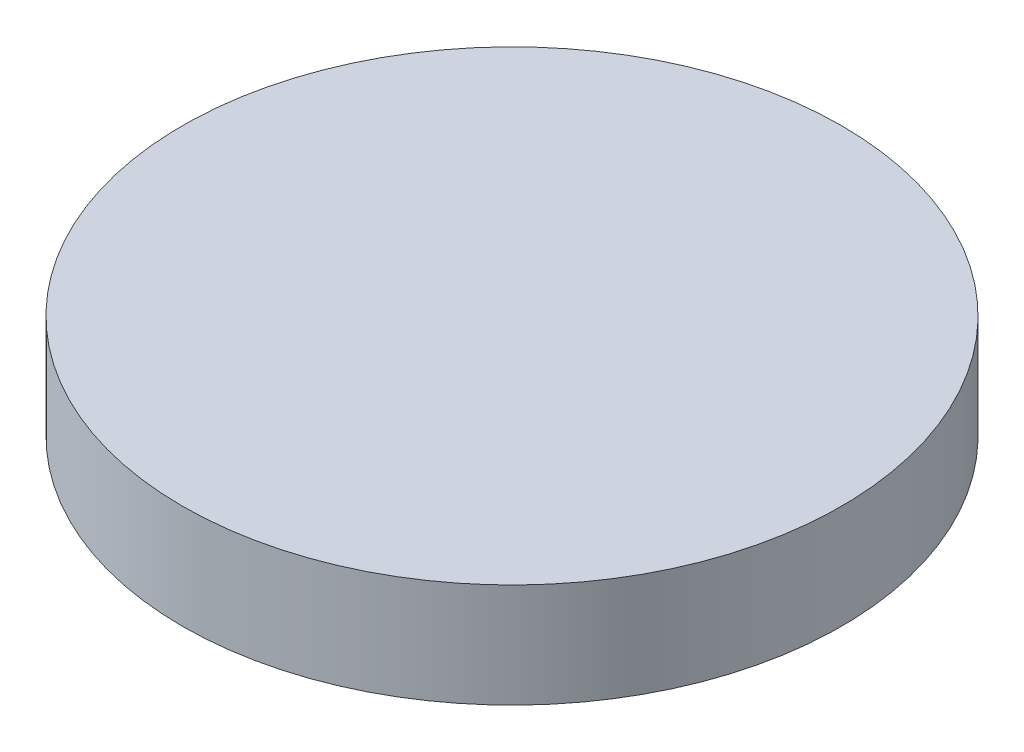
from build123d import *

# Parameters (mm, degrees)
SKETCH1_R           = 60.325
BOSS_EXTRUDE1_DEPTH = 19.05
SKETCH2_R           = 57.15
SKETCH2_R_2         = 55.5625
CUT_EXTRUDE1_DEPTH  = 3.175
SKETCH3_W           = 9.697234664
SKETCH3_H           = 6.926230082
CUT_EXTRUDE2_DEPTH  = 2.54


with BuildPart() as part:
    # Sketch1 → Boss-Extrude1 (new body)
    with BuildSketch(Plane(origin=(0, 0, 0), x_dir=(1, 0, 0), z_dir=(0, 1, 0))):
        Circle(SKETCH1_R)
    extrude(amount=BOSS_EXTRUDE1_DEPTH)

    # Sketch2 → Cut-Extrude1 (cut)
    with BuildSketch(Plane.XZ):
        Circle(SKETCH2_R)
        Circle(SKETCH2_R_2, mode=Mode.SUBTRACT)
    extrude(amount=-CUT_EXTRUDE1_DEPTH, mode=Mode.SUBTRACT)

    # Sketch3 → Cut-Extrude2 (cut)
    with BuildSketch(Plane.XZ):
        Rectangle(SKETCH3_W, SKETCH3_H)
    extrude(amount=-CUT_EXTRUDE2_DEPTH, mode=Mode.SUBTRACT)


solid = part.part
